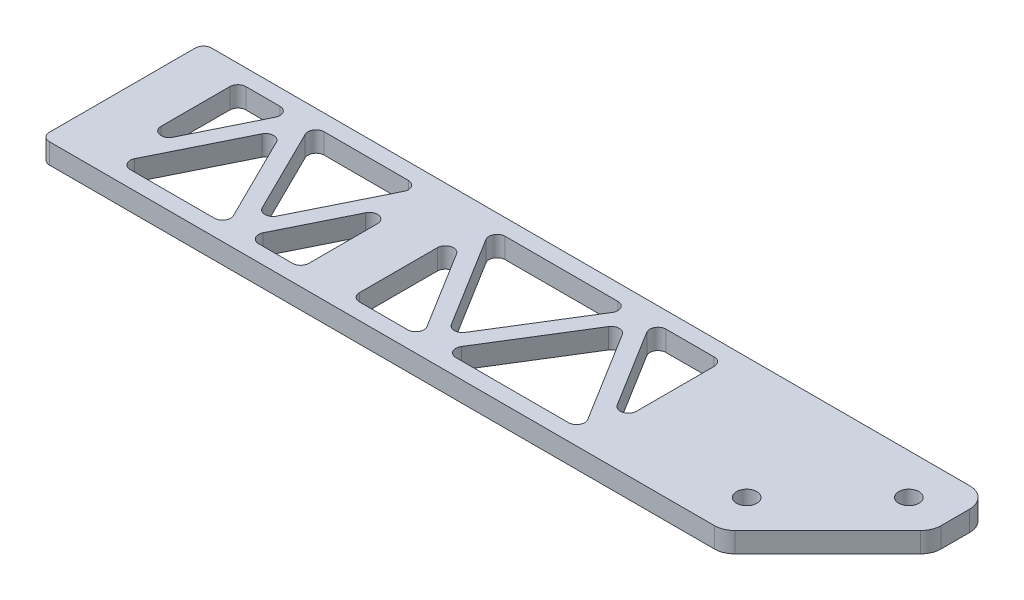
from build123d import *

# Parameters (mm, degrees)
SKETCH1_R           = 3.175
BOSS_EXTRUDE1_DEPTH = 3.175
FILLET1_R           = 2.54
FILLET2_R           = 6.35


with BuildPart() as part:
    # Sketch1 → Boss-Extrude1 (new body, symmetric)
    with BuildSketch(Plane(origin=(0, 0, 0), x_dir=(1, 0, 0), z_dir=(0, 1, 0))):
        Polygon((121.465512242, -25.4), (154.305, 7.439487758), (154.305, 25.4), (-92.075, 25.4), (-92.075, -25.4), align=None)
        Polygon((-38.817248104, -20.32), (-73.366085229, -20.32), (-56.091666667, 14.592509095), align=None, mode=Mode.SUBTRACT)
        Polygon((-15.875, 14.592509095), (-15.875, -20.32), (-33.149418563, -20.32), align=None, mode=Mode.SUBTRACT)
        Polygon((22.200034711, -20.32), (0, -20.32), (0, 15.498543399), align=None, mode=Mode.SUBTRACT)
        with Locations((116.205, -12.7)):
            Circle(SKETCH1_R, mode=Mode.SUBTRACT)
        Polygon((72.576701378, -20.32), (28.176631956, -20.32), (50.376666667, 15.498543399), align=None, mode=Mode.SUBTRACT)
        Polygon((53.364965289, 20.32), (75.565, 20.32), (75.565, -15.498543399), align=None, mode=Mode.SUBTRACT)
        Polygon((-76.2, -14.592509095), (-76.2, 20.32), (-58.925581437, 20.32), align=None, mode=Mode.SUBTRACT)
        Polygon((-53.257751896, 20.32), (-18.708914771, 20.32), (-35.983333333, -14.592509095), align=None, mode=Mode.SUBTRACT)
        Polygon((2.988298622, 20.32), (47.388368044, 20.32), (25.188333333, -15.498543399), align=None, mode=Mode.SUBTRACT)
        with Locations((141.605, 12.7)):
            Circle(SKETCH1_R, mode=Mode.SUBTRACT)
    extrude(amount=BOSS_EXTRUDE1_DEPTH, both=True)

    # Fillet1
    fillet1_edges = [part.edges().sort_by_distance(p)[0] for p in [
        (-76.2, 0, -20.32),
        (-76.2, 0, 14.592509095),
        (-58.925581437, 0, -20.32),
        (2.988298622, 0, -20.32),
        (25.188333333, 0, 15.498543399),
        (47.388368044, 0, -20.32),
        (0, 0, -15.498543399),
        (0, 0, 20.32),
        (22.200034711, 0, 20.32),
        (72.576701378, 0, 20.32),
        (50.376666667, 0, -15.498543399),
        (28.176631956, 0, 20.32),
        (75.565, 0, 15.498543399),
        (75.565, 0, -20.32),
        (53.364965289, 0, -20.32),
        (-15.875, 0, 20.32),
        (-15.875, 0, -14.592509095),
        (-33.149418563, 0, 20.32),
        (-35.983333333, 0, 14.592509095),
        (-18.708914771, 0, -20.32),
        (-53.257751896, 0, -20.32),
        (-92.075, 0, 25.4),
        (-92.075, 0, -25.4),
        (-38.817248104, 0, 20.32),
        (-56.091666667, 0, -14.592509095),
        (-73.366085229, 0, 20.32),
    ]]
    fillet(fillet1_edges, radius=FILLET1_R)

    # Fillet2
    fillet2_edges = [part.edges().sort_by_distance(p)[0] for p in [
        (154.305, 0, -25.4),
        (154.305, 0, -7.439487758),
        (121.465512242, 0, 25.4),
    ]]
    fillet(fillet2_edges, radius=FILLET2_R)


solid = part.part
